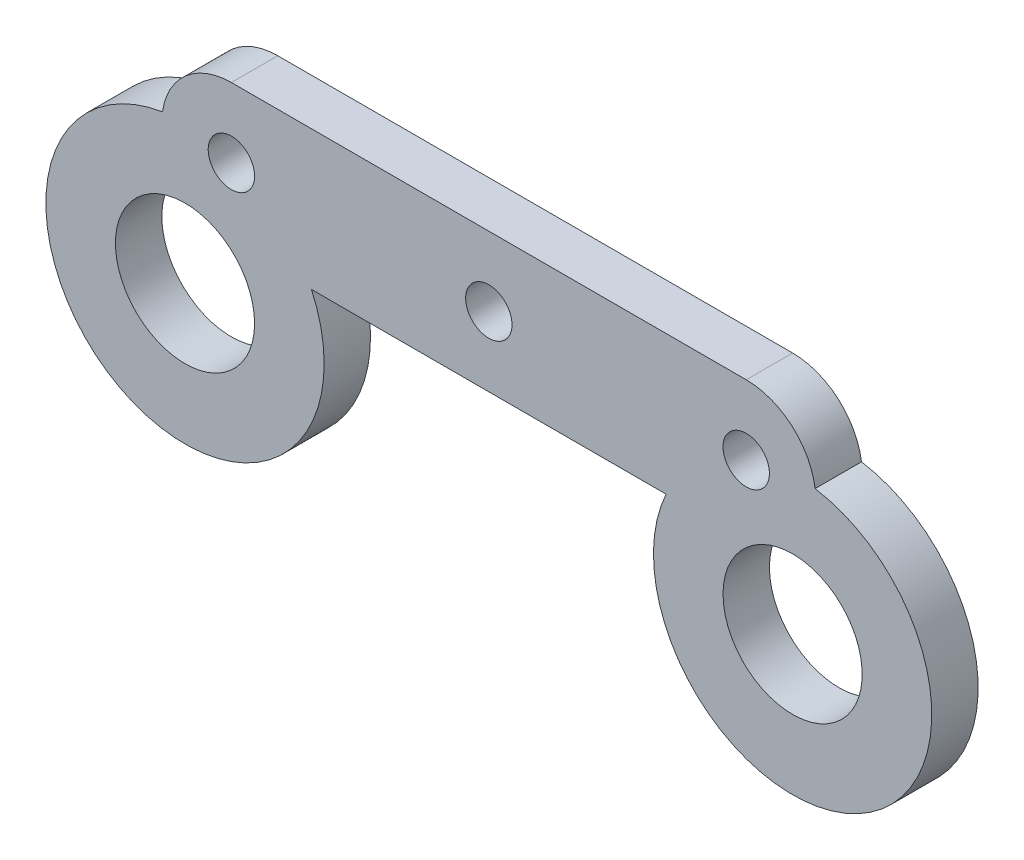
from build123d import *

# Parameters (mm, degrees)
SKETCH1_R           = 1
SKETCH1_R_2         = 3
BOSS_EXTRUDE1_DEPTH = 2
SKETCH2_R           = 0.5
CUT_EXTRUDE1_DEPTH  = 0.5


with BuildPart() as part:
    # Sketch1 → Boss-Extrude1 (new body)
    with BuildSketch(Plane.XY):
        with BuildLine():
            Line((-11.100190374, 3), (11.100190374, 3))
            ThreePointArc((11.100190374, 3), (13.067032348, 2.265288646), (14.070500235, 0.421021768))
            ThreePointArc((14.070500235, 0.421021768), (15.920210774, -10.795987627), (7.645834317, -3))
            Line((7.645834317, -3), (-7.645834317, -3))
            ThreePointArc((-7.645834317, -3), (-15.920210774, -10.795987627), (-14.070500235, 0.421021768))
            ThreePointArc((-14.070500235, 0.421021768), (-13.067032348, 2.265288646), (-11.100190374, 3))
        make_face()
        Circle(SKETCH1_R, mode=Mode.SUBTRACT)
        with Locations((-13.100190374, -5.5)):
            Circle(SKETCH1_R_2, mode=Mode.SUBTRACT)
        with Locations((13.100190374, -5.5)):
            Circle(SKETCH1_R_2, mode=Mode.SUBTRACT)
        with Locations((-11.100190374, 0)):
            Circle(SKETCH1_R, mode=Mode.SUBTRACT)
        with Locations((11.100190374, 0)):
            Circle(SKETCH1_R, mode=Mode.SUBTRACT)
    extrude(amount=BOSS_EXTRUDE1_DEPTH)

    # Sketch2 → Cut-Extrude1 (cut)
    with BuildSketch(Plane.XZ.offset(3)):
        with Locations((0, 1)):
            Circle(SKETCH2_R)
    extrude(amount=-CUT_EXTRUDE1_DEPTH, mode=Mode.SUBTRACT)


solid = part.part
